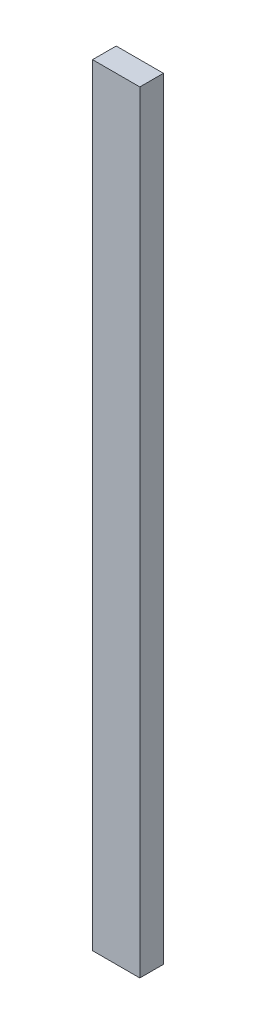
from build123d import *

# Parameters (mm, degrees)
SKETCH1_W           = 30
SKETCH1_H           = 15
BOSS_EXTRUDE1_DEPTH = 490


with BuildPart() as part:
    # Sketch1 → Boss-Extrude1 (new body)
    with BuildSketch(Plane(origin=(0, 0, 0), x_dir=(1, 0, 0), z_dir=(0, 1, 0))):
        with Locations((15, 7.5)):
            Rectangle(SKETCH1_W, SKETCH1_H)
    extrude(amount=BOSS_EXTRUDE1_DEPTH)


solid = part.part
